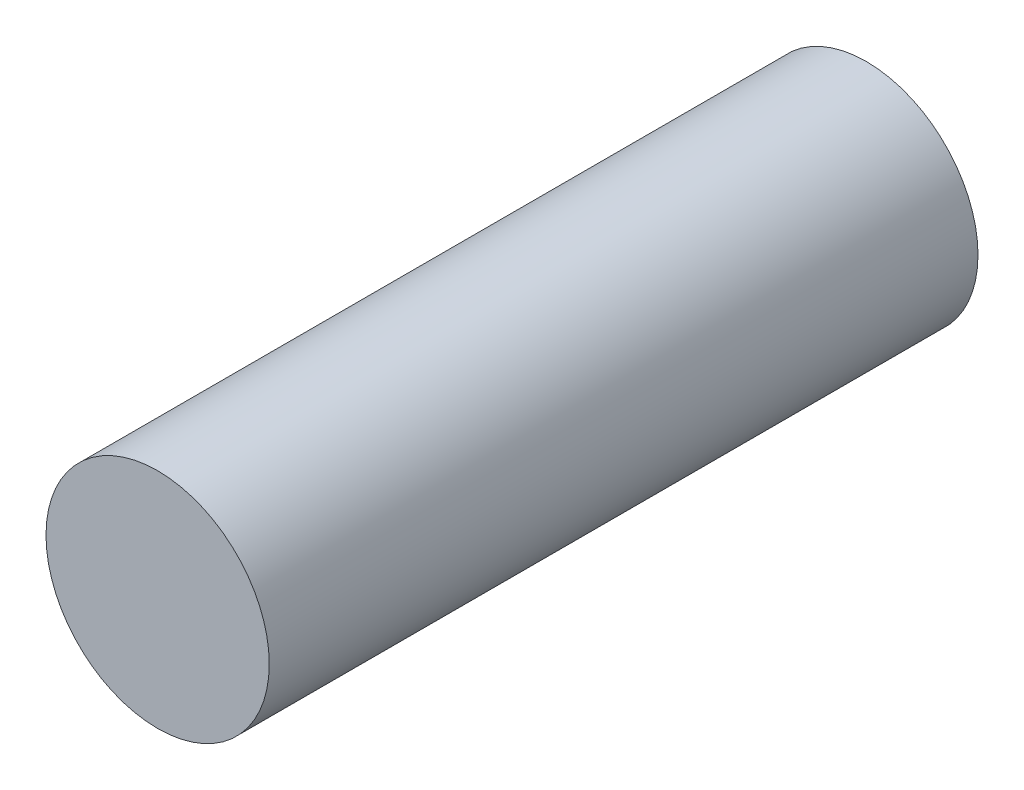
from build123d import *

# Parameters (mm, degrees)
SKETCH1_R           = 16.002
BOSS_EXTRUDE1_DEPTH = 101.6


with BuildPart() as part:
    # Sketch1 → Boss-Extrude1 (new body)
    with BuildSketch(Plane.XY):
        Circle(SKETCH1_R)
    extrude(amount=BOSS_EXTRUDE1_DEPTH)


solid = part.part
